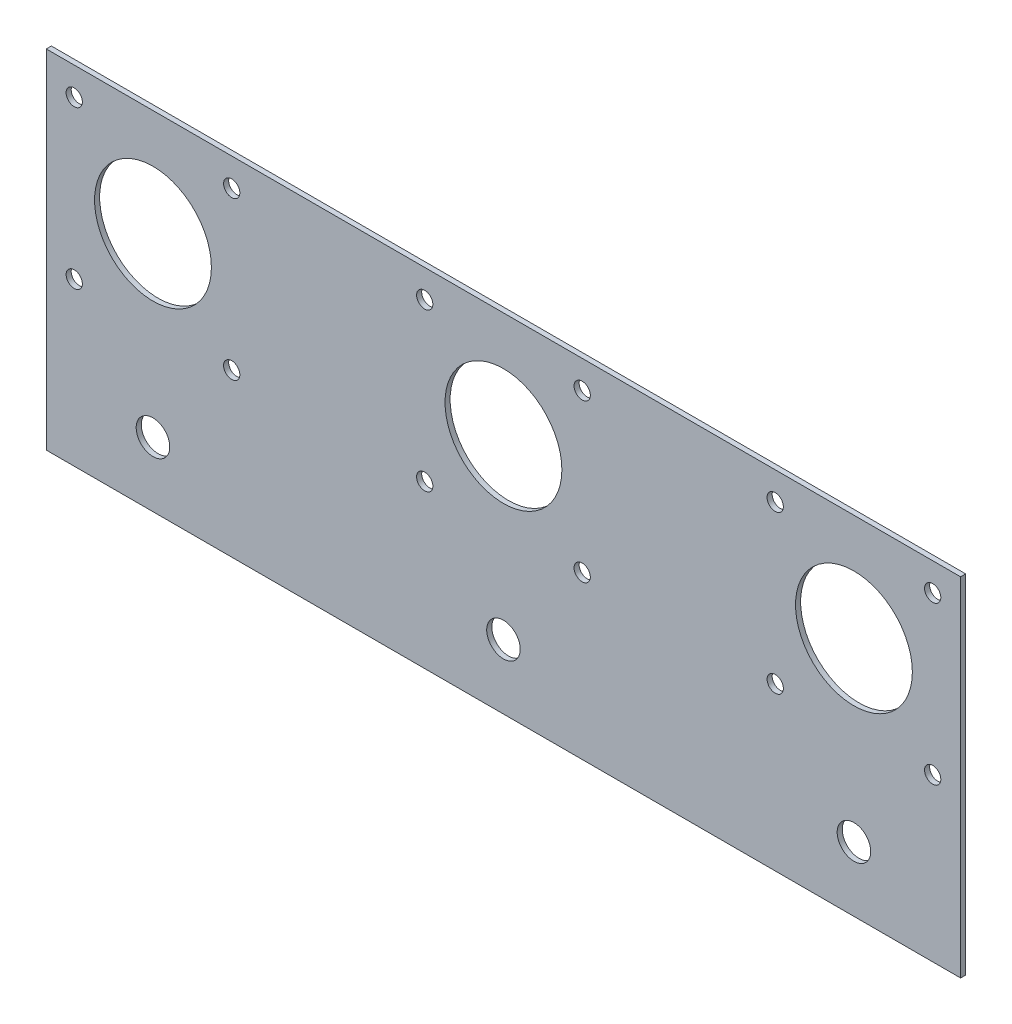
from build123d import *

# Parameters (mm, degrees)
SKETCH1_W           = 180
SKETCH1_H           = 68.4
SKETCH1_R           = 3.302
BOSS_EXTRUDE1_DEPTH = 1
SKETCH2_R           = 11.5
SKETCH2_R_2         = 1.6
CUT_EXTRUDE1_DEPTH  = 1
LPATTERN1_COUNT     = 3
LPATTERN1_PITCH     = 69


with BuildPart() as part:
    # Sketch1 → Boss-Extrude1 (new body)
    with BuildSketch(Plane.XY):
        with Locations((90, 34.2)):
            Rectangle(SKETCH1_W, SKETCH1_H)
        with Locations((21, 12.7)):
            Circle(SKETCH1_R, mode=Mode.SUBTRACT)
        with Locations((90, 12.7)):
            Circle(SKETCH1_R, mode=Mode.SUBTRACT)
        with Locations((159, 12.7)):
            Circle(SKETCH1_R, mode=Mode.SUBTRACT)
    extrude(amount=BOSS_EXTRUDE1_DEPTH)

    # Sketch2 → Cut-Extrude1 (cut)
    with BuildSketch(Plane.XY.offset(1)):
        with Locations((21, 47.4)):
            Circle(SKETCH2_R)
        with Locations((36.5, 62.9)):
            Circle(SKETCH2_R_2)
        with Locations((36.5, 31.9)):
            Circle(SKETCH2_R_2)
        with Locations((5.5, 31.9)):
            Circle(SKETCH2_R_2)
        with Locations((5.5, 62.9)):
            Circle(SKETCH2_R_2)
    cut_extrude1 = extrude(amount=-CUT_EXTRUDE1_DEPTH, mode=Mode.SUBTRACT)

    # LPattern1: Cut-Extrude1 ×3
    with Locations(*[(i * LPATTERN1_PITCH, 0, 0) for i in range(1, LPATTERN1_COUNT)]):
        add(cut_extrude1, mode=Mode.SUBTRACT)


solid = part.part
